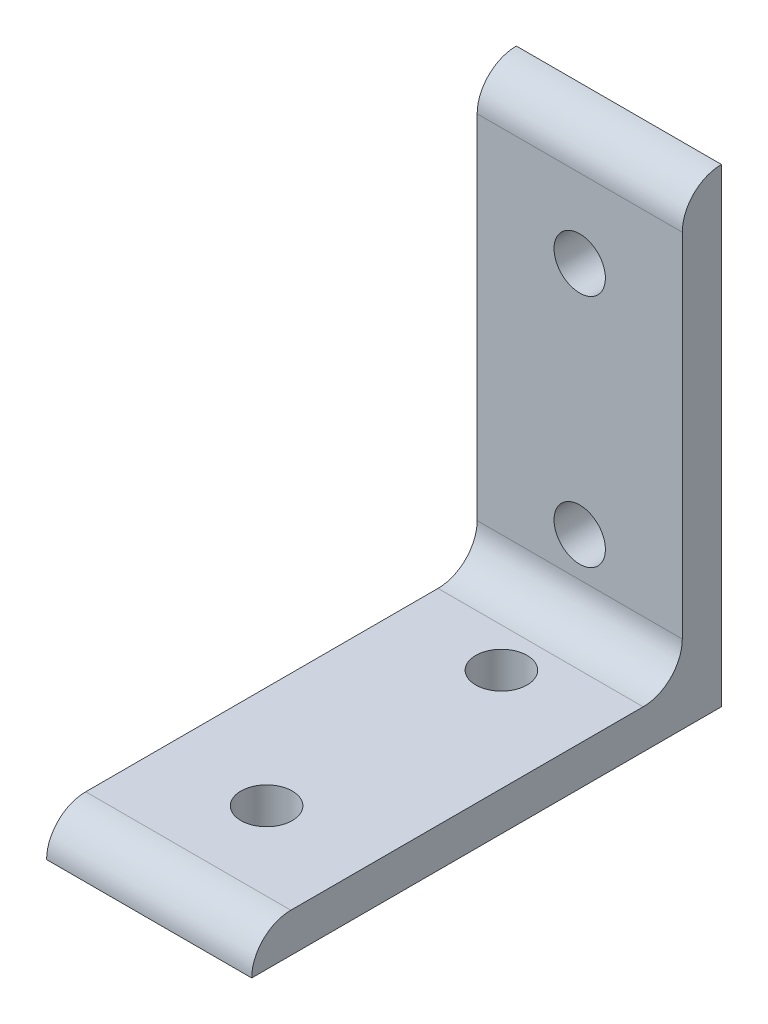
from build123d import *

# Parameters (mm, degrees)
BASE_EXTRUDE_DEPTH       = 16.637
SKETCH2_R                = 4.1656
HOLE1_DEPTH              = 110.03976233
HOLE1_PATTERN_COUNT      = 2
HOLE1_PATTERN_PITCH      = 38.1
HOLE1_PATTERN_COUNT_DIR2 = 2
HOLE1_PATTERN_PITCH_DIR2 = 38.1
SKETCH3_R                = 4.1656
HOLE2_DEPTH              = 110.03976233
HOLE2_PATTERN_COUNT      = 2
HOLE2_PATTERN_PITCH      = 38.1
HOLE2_PATTERN_COUNT_DIR2 = 2
HOLE2_PATTERN_PITCH_DIR2 = 38.1


with BuildPart() as part:
    # Sketch1 → Base Extrude (new, symmetric)
    with BuildSketch(Plane(origin=(0, 0, 0), x_dir=(0, 0, -1), z_dir=(1, 0, 0))):
        with BuildLine():
            Line((-6.35, 12.7), (-6.35, 69.85))
            ThreePointArc((-6.35, 69.85), (-4.490128061, 74.340128061), (0, 76.2))
            Line((0, 76.2), (0, 0))
            Line((0, 0), (-76.2, 0))
            ThreePointArc((-76.2, 0), (-74.340128061, 4.490128061), (-69.85, 6.35))
            Line((-69.85, 6.35), (-12.7, 6.35))
            ThreePointArc((-12.7, 6.35), (-8.209871939, 8.209871939), (-6.35, 12.7))
        make_face()
    extrude(amount=BASE_EXTRUDE_DEPTH, both=True)

    # Sketch2 → Hole1 (cut, through all)
    with BuildSketch(Plane.XZ):
        with Locations(Location((0, 19.05, 0), (0, 0, 270))):
            Circle(SKETCH2_R)
    hole1 = extrude(amount=-HOLE1_DEPTH, mode=Mode.SUBTRACT)

    # Hole1 Pattern: Hole1 2 × 2
    with Locations(*[(i * HOLE1_PATTERN_PITCH, 0, j * HOLE1_PATTERN_PITCH_DIR2) for i in range(HOLE1_PATTERN_COUNT) for j in range(HOLE1_PATTERN_COUNT_DIR2) if (i, j) != (0, 0)]):
        add(hole1, mode=Mode.SUBTRACT)

    # Sketch3 → Hole2 (cut, through all)
    with BuildSketch(Plane(origin=(0, 0, 0), x_dir=(-1, 0, 0), z_dir=(0, 0, -1))):
        with Locations(Location((0, 19.05, 0), (0, 0, 90))):
            Circle(SKETCH3_R)
    hole2 = extrude(amount=-HOLE2_DEPTH, mode=Mode.SUBTRACT)

    # Hole2 Pattern: Hole2 2 × 2
    with Locations(*[(i * HOLE2_PATTERN_PITCH, j * HOLE2_PATTERN_PITCH_DIR2, 0) for i in range(HOLE2_PATTERN_COUNT) for j in range(HOLE2_PATTERN_COUNT_DIR2) if (i, j) != (0, 0)]):
        add(hole2, mode=Mode.SUBTRACT)


solid = part.part
